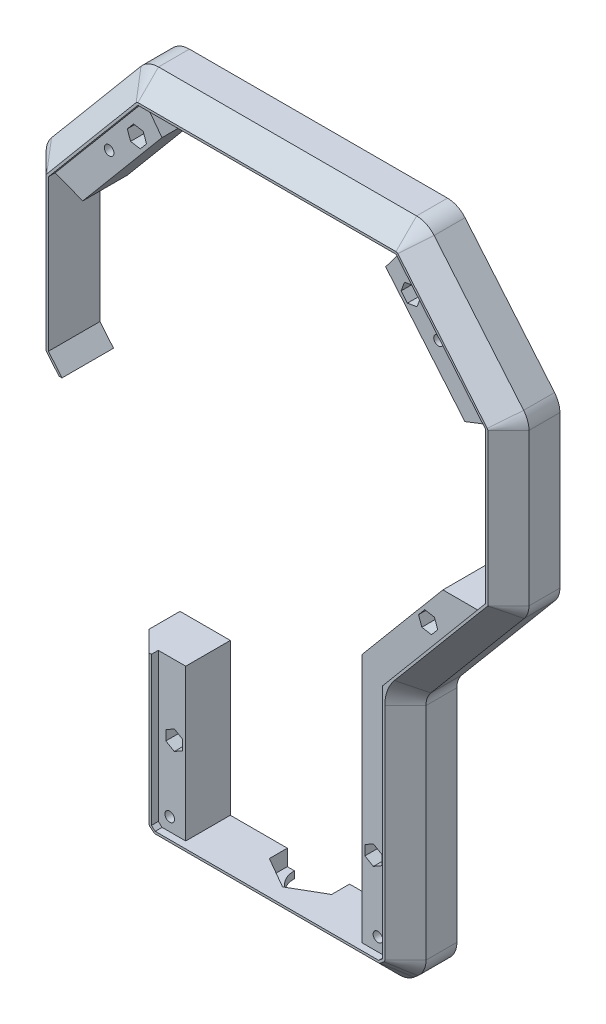
from build123d import *

# Parameters (mm, degrees)
RESSALTO_EXTRUS_O1_DEPTH = 22.5
CHANFRO1_SIZE            = 9
CORTE_EXTRUS_O1_REACH    = 24.5
ESBO_O3_W                = 1139.230904301
ESBO_O3_H                = 709.798033895
CORTE_EXTRUS_O5_DEPTH    = 3
CORTE_EXTRUS_O6_REACH    = 21.5
ESBO_O5_W                = 77
ESBO_O5_H                = 10
ESBO_O7_R                = 2.1
ESBO_O7_R_2              = 2.15
CORTE_EXTRUS_O7_DEPTH    = 23.5
CORTE_EXTRUS_O8_DEPTH    = 10
ESBO_O9_W                = 92.788829696
ESBO_O9_H                = 85.062360753
CORTE_EXTRUS_O9_DEPTH    = 23.5
CORTE_EXTRUS_O10_REACH   = 21.5
CORTE_EXTRUS_O11_DEPTH   = 7
ESBO_O12_R               = 10.5
CORTE_EXTRUS_O12_DEPTH   = 7
CORTE_EXTRUS_O13_DEPTH   = 10


with BuildPart() as part:
    # Esboço1 → Ressalto-extrusão1 (new body, symmetric)
    with BuildSketch(Plane.XY):
        with BuildLine():
            Line((-56.387503511, 290.197344596), (56.387503511, 290.197344596))
            ThreePointArc((56.387503511, 290.197344596), (60.613686129, 289.260422466), (64.047947942, 286.625220692))
            Line((64.047947942, 286.625220692), (103.160444431, 240.012762487))
            ThreePointArc((103.160444431, 240.012762487), (104.896926208, 237.005087823), (105.5, 233.58488639))
            Line((105.5, 233.58488639), (105.5, 167.188670131))
            ThreePointArc((105.5, 167.188670131), (104.953136861, 164.08725515), (103.378507208, 161.359916588))
            Line((103.378507208, 161.359916588), (62.621492792, 112.787598236))
            ThreePointArc((62.621492792, 112.787598236), (61.046863139, 110.060259674), (60.5, 106.958844693))
            Line((60.5, 106.958844693), (60.5, 10.605625498))
            ThreePointArc((60.5, 10.605625498), (59.56307787, 6.379442881), (56.927876097, 2.945181067))
            Line((56.927876097, 2.945181067), (55.249552272, 1.536900164))
            ThreePointArc((55.249552272, 1.536900164), (52.241877608, -0.199581612), (48.821676175, -0.802655404))
            Line((48.821676175, -0.802655404), (-48.821676175, -0.802655404))
            ThreePointArc((-48.821676175, -0.802655404), (-52.241877608, -0.199581612), (-55.249552272, 1.536900164))
            Line((-55.249552272, 1.536900164), (-56.927876097, 2.945181067))
            ThreePointArc((-56.927876097, 2.945181067), (-59.56307787, 6.379442881), (-60.5, 10.605625498))
            Line((-60.5, 10.605625498), (-60.5, 106.958844693))
            ThreePointArc((-60.5, 106.958844693), (-61.046863139, 110.060259674), (-62.621492792, 112.787598236))
            Line((-62.621492792, 112.787598236), (-103.378507208, 161.359916588))
            ThreePointArc((-103.378507208, 161.359916588), (-104.953136861, 164.08725515), (-105.5, 167.188670131))
            Line((-105.5, 167.188670131), (-105.5, 233.58488639))
            ThreePointArc((-105.5, 233.58488639), (-104.896926208, 237.005087823), (-103.160444431, 240.012762487))
            Line((-103.160444431, 240.012762487), (-64.047947942, 286.625220692))
            ThreePointArc((-64.047947942, 286.625220692), (-60.613686129, 289.260422466), (-56.387503511, 290.197344596))
        make_face()
        Polygon((-48.869071975, 270.197344596), (48.869071975, 270.197344596), (83.5, 228.925811707), (83.5, 171.895558399), (38.5, 118.266646732), (38.5, 19.197344596), (-38.5, 19.197344596), (-38.5, 118.266646732), (-83.5, 171.895558399), (-83.5, 228.925811707), align=None, mode=Mode.SUBTRACT)
    extrude(amount=RESSALTO_EXTRUS_O1_DEPTH, both=True)

    # Chanfro1
    chanfro1_edges = [part.edges().sort_by_distance(p)[0] for p in [
        (83.604196187, 263.318991589, 22.5),
        (60.613686129, 289.260422466, 22.5),
        (0, 290.197344596, 22.5),
        (-60.613686129, 289.260422466, 22.5),
        (-83.604196187, 263.318991589, 22.5),
        (-104.896926208, 237.005087823, 22.5),
        (-105.5, 200.38677826, 22.5),
        (-104.953136861, 164.08725515, 22.5),
        (-83, 137.073757412, 22.5),
        (-61.046863139, 110.060259674, 22.5),
        (-60.5, 58.782235095, 22.5),
        (-59.56307787, 6.379442881, 22.5),
        (-56.088714184, 2.241040616, 22.5),
        (-52.241877608, -0.199581612, 22.5),
        (0, -0.802655404, 22.5),
        (52.241877608, -0.199581612, 22.5),
        (56.088714184, 2.241040616, 22.5),
        (59.56307787, 6.379442881, 22.5),
        (60.5, 58.782235095, 22.5),
        (61.046863139, 110.060259674, 22.5),
        (83, 137.073757412, 22.5),
        (104.953136861, 164.08725515, 22.5),
        (105.5, 200.38677826, 22.5),
        (104.896926208, 237.005087823, 22.5),
    ]]
    chamfer(chanfro1_edges, length=CHANFRO1_SIZE)

    # Esboço3 → Corte-extrusão1 (cut, up to next)
    with BuildSketch(Plane.XY, mode=Mode.PRIVATE) as corte_extrus_o1_sk1:
        with Locations((-153.157436203, 152.53565808)):
            Rectangle(ESBO_O3_W, ESBO_O3_H)
    corte_extrus_o1_tool1 = extrude(corte_extrus_o1_sk1.sketch, amount=-CORTE_EXTRUS_O1_REACH, mode=Mode.PRIVATE) & part.part
    add(corte_extrus_o1_tool1.solids().sort_by_distance((-153.157436, 152.535658, 0))[0], mode=Mode.SUBTRACT)

    # Esboço4 → Corte-extrusão5 (cut)
    with BuildSketch(Plane.XY.offset(22.5)):
        Polygon((56.387503511, 280.197344596), (-56.387503511, 280.197344596), (-95.5, 233.58488639), (-95.5, 167.527915588), (-50.5, 113.899003921), (-50.5, 10.605625498), (-48.821676175, 9.197344596), (48.821676175, 9.197344596), (50.5, 10.605625498), (50.5, 113.899003921), (95.5, 167.527915588), (95.5, 233.58488639), align=None)
        Polygon((38.5, 19.197344596), (-38.5, 19.197344596), (-38.5, 121.489121124), (-83.5, 175.11803279), (-83.5, 228.925811707), (-48.869071975, 270.197344596), (48.869071975, 270.197344596), (83.5, 228.925811707), (83.5, 175.11803279), (38.5, 121.489121124), align=None, mode=Mode.SUBTRACT)
    extrude(amount=-CORTE_EXTRUS_O5_DEPTH, mode=Mode.SUBTRACT)

    # Esboço5 → Corte-extrusão6 (cut, up to next)
    with BuildSketch(Plane.XY.offset(19.5), mode=Mode.PRIVATE) as corte_extrus_o6_sk1:
        Polygon((-95.5, 233.58488639), (-83.5, 228.925811707), (-83.5, 171.895558399), (-95.5, 167.527915588), align=None)
    corte_extrus_o6_tool1 = extrude(corte_extrus_o6_sk1.sketch, amount=-CORTE_EXTRUS_O6_REACH, mode=Mode.PRIVATE) & part.part
    add(corte_extrus_o6_tool1.solids().sort_by_distance((-89.646672, 200.485324, 19.5))[0], mode=Mode.SUBTRACT)
    # Esboço5 → Corte-extrusão6 (cut, up to next)
    with BuildSketch(Plane.XY.offset(19.5), mode=Mode.PRIVATE) as corte_extrus_o6_sk2:
        Polygon((-48.869071975, 270.197344596), (-56.387503511, 280.197344596), (56.387503511, 280.197344596), (48.869071975, 270.197344596), align=None)
    corte_extrus_o6_tool2 = extrude(corte_extrus_o6_sk2.sketch, amount=-CORTE_EXTRUS_O6_REACH, mode=Mode.PRIVATE) & part.part
    add(corte_extrus_o6_tool2.solids().sort_by_distance((0, 275.316394, 19.5))[0], mode=Mode.SUBTRACT)
    # Esboço5 → Corte-extrusão6 (cut, up to next)
    with BuildSketch(Plane.XY.offset(19.5), mode=Mode.PRIVATE) as corte_extrus_o6_sk3:
        with Locations((0, 14.197344596)):
            Rectangle(ESBO_O5_W, ESBO_O5_H)
    corte_extrus_o6_tool3 = extrude(corte_extrus_o6_sk3.sketch, amount=-CORTE_EXTRUS_O6_REACH, mode=Mode.PRIVATE) & part.part
    add(corte_extrus_o6_tool3.solids().sort_by_distance((0, 14.197345, 19.5))[0], mode=Mode.SUBTRACT)
    # Esboço5 → Corte-extrusão6 (cut, up to next)
    with BuildSketch(Plane.XY.offset(19.5), mode=Mode.PRIVATE) as corte_extrus_o6_sk4:
        Polygon((83.5, 171.895558399), (95.5, 167.527915588), (95.5, 233.58488639), (83.5, 228.925811707), align=None)
    corte_extrus_o6_tool4 = extrude(corte_extrus_o6_sk4.sketch, amount=-CORTE_EXTRUS_O6_REACH, mode=Mode.PRIVATE) & part.part
    add(corte_extrus_o6_tool4.solids().sort_by_distance((89.646672, 200.485324, 19.5))[0], mode=Mode.SUBTRACT)

    # Esboço7 → Corte-extrusão7 (cut, through all)
    with BuildSketch(Plane.XY.offset(22.5)):
        with Locations((-45.5, 14.923339275)):
            Circle(ESBO_O7_R)
        with Locations((-43.5, 44.856598369)):
            Circle(ESBO_O7_R_2)
        with Locations((-71.975269931, 253.84194883)):
            Circle(ESBO_O7_R)
        with Locations((-59.836146954, 265.197344596)):
            Circle(ESBO_O7_R_2)
        with Locations((59.836146954, 265.197344596)):
            Circle(ESBO_O7_R_2)
        with Locations((71.975269931, 253.84194883)):
            Circle(ESBO_O7_R)
        with Locations((43.5, 44.856598369)):
            Circle(ESBO_O7_R_2)
        with Locations((45.5, 14.923339275)):
            Circle(ESBO_O7_R)
        with Locations((-67.431100943, 144.966771084)):
            Circle(ESBO_O7_R_2)
        with Locations((67.431100943, 144.966771084)):
            Circle(ESBO_O7_R_2)
    extrude(amount=-CORTE_EXTRUS_O7_DEPTH, mode=Mode.SUBTRACT)

    # Esboço8 → Corte-extrusão8 (cut)
    with BuildSketch(Plane(origin=(0, 0, 0), x_dir=(-1, 0, 0), z_dir=(0, 0, -1))):
        Polygon((-73.397020968, 257.748177701), (-76.069038884, 254.56379075), (-74.647287847, 250.657561879), (-70.553518893, 249.93571996), (-67.881500977, 253.120106911), (-69.303252014, 257.026335782), align=None)
        Polygon((-45.5, 19.080261213), (-49.1, 17.001800244), (-49.1, 12.844878306), (-45.5, 10.766417337), (-41.9, 12.844878306), (-41.9, 17.001800244), align=None)
        Polygon((41.9, 17.001800244), (45.5, 19.080261213), (49.1, 17.001800244), (49.1, 12.844878306), (45.5, 10.766417337), (41.9, 12.844878306), align=None)
        Polygon((76.069038884, 254.56379075), (73.397020968, 257.748177701), (69.303252014, 257.026335782), (67.881500977, 253.120106911), (70.553518893, 249.93571996), (74.647287847, 250.657561879), align=None)
        Polygon((67.580931876, 147.478918378), (71.560985025, 146.777127623), (72.943242978, 142.97940511), (70.345447782, 139.883473352), (66.365394632, 140.585264107), (64.98313668, 144.38298662), align=None)
    extrude(amount=-CORTE_EXTRUS_O8_DEPTH, mode=Mode.SUBTRACT)

    # Esboço9 → Corte-extrusão9 (cut, through all)
    with BuildSketch(Plane.XY.offset(22.5)):
        with Locations((-70.062226852, 117.896927121)):
            Rectangle(ESBO_O9_W, ESBO_O9_H)
    extrude(amount=-CORTE_EXTRUS_O9_DEPTH, mode=Mode.SUBTRACT)

    # Esboço10 → Corte-extrusão10 (cut, up to next)
    with BuildSketch(Plane.XY.offset(19.5), mode=Mode.PRIVATE) as corte_extrus_o10_sk1:
        Polygon((-95.5, 167.527915588), (-83.5, 171.895558399), (-73.877666178, 160.428107498), (-89.54255365, 160.428107498), align=None)
    corte_extrus_o10_tool1 = extrude(corte_extrus_o10_sk1.sketch, amount=-CORTE_EXTRUS_O10_REACH, mode=Mode.PRIVATE) & part.part
    add(corte_extrus_o10_tool1.solids().sort_by_distance((-85.062746, 165.15554, 19.5))[0], mode=Mode.SUBTRACT)
    # Esboço10 → Corte-extrusão10 (cut, up to next)
    with BuildSketch(Plane.XY.offset(19.5), mode=Mode.PRIVATE) as corte_extrus_o10_sk2:
        Polygon((89.54255365, 160.428107498), (95.5, 167.527915588), (83.5, 171.895558399), (73.877666178, 160.428107498), align=None)
    corte_extrus_o10_tool2 = extrude(corte_extrus_o10_sk2.sketch, amount=-CORTE_EXTRUS_O10_REACH, mode=Mode.PRIVATE) & part.part
    add(corte_extrus_o10_tool2.solids().sort_by_distance((85.062746, 165.15554, 19.5))[0], mode=Mode.SUBTRACT)

    # Esboço11 → Corte-extrusão11 (cut)
    with BuildSketch(Plane(origin=(0, 9.197344596, 0), x_dir=(1, 0, 0), z_dir=(0, 1, 0))):
        Polygon((0, -15.703927322), (13.6, -7.851963661), (13.6, 7.851963661), (0, 15.703927322), (-13.6, 7.851963661), (-13.6, -7.851963661), align=None)
    extrude(amount=-CORTE_EXTRUS_O11_DEPTH, mode=Mode.SUBTRACT)

    # Esboço12 → Corte-extrusão12 (cut)
    with BuildSketch(Plane.XZ.offset(0.802655404)):
        Circle(ESBO_O12_R)
    extrude(amount=-CORTE_EXTRUS_O12_DEPTH, mode=Mode.SUBTRACT)

    # Esboço13 → Corte-extrusão13 (cut)
    with BuildSketch(Plane.XY.offset(19.5)):
        Polygon((-57.089906317, 268.47018674), (-61.297391075, 269.212079824), (-64.043631711, 265.939237679), (-62.58238759, 261.924502451), (-58.374902832, 261.182609368), (-55.628662196, 264.455451512), align=None)
        Polygon((61.297391075, 269.212079824), (57.089906317, 268.47018674), (55.628662196, 264.455451512), (58.374902832, 261.182609368), (62.58238759, 261.924502451), (64.043631711, 265.939237679), align=None)
        Polygon((-47.2, 46.992794365), (-47.2, 42.720402373), (-43.5, 40.584206377), (-39.8, 42.720402373), (-39.8, 46.992794365), (-43.5, 49.128990361), align=None)
        Polygon((47.2, 46.992794365), (43.5, 49.128990361), (39.8, 46.992794365), (39.8, 42.720402373), (43.5, 40.584206377), (47.2, 42.720402373), align=None)
        Polygon((70.177341579, 148.239613229), (65.969856821, 148.981506312), (63.223616185, 145.708664168), (64.684860306, 141.69392894), (68.892345064, 140.952035856), (71.6385857, 144.224878001), align=None)
    extrude(amount=-CORTE_EXTRUS_O13_DEPTH, mode=Mode.SUBTRACT)


solid = part.part
